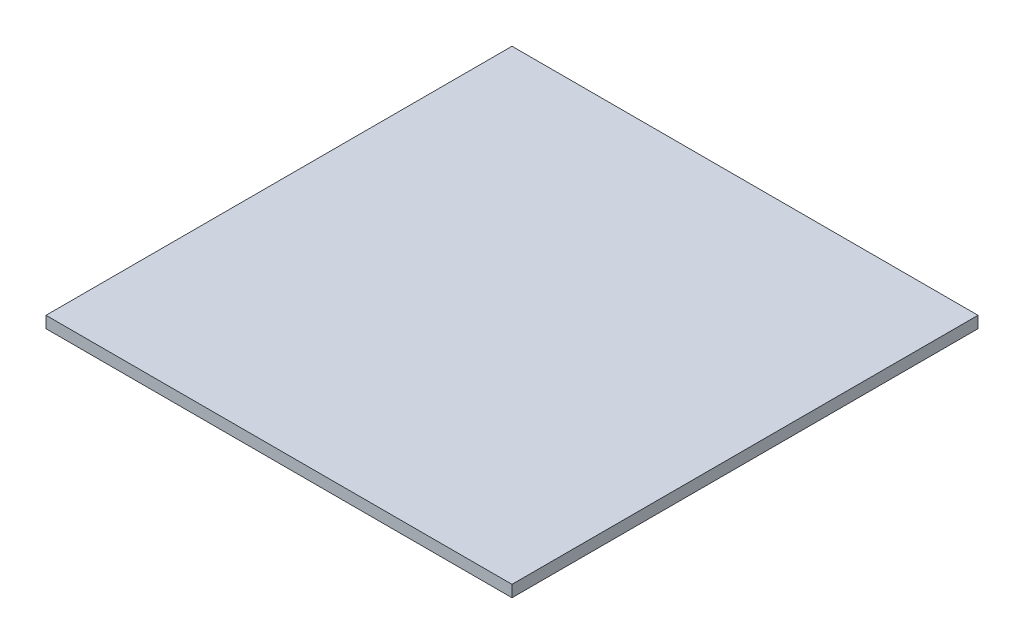
from build123d import *

# Parameters (mm, degrees)
SKETCH_1_W      = 80
SKETCH_1_H      = 80
EXTRUDE_1_DEPTH = 2


with BuildPart() as part:
    # 草图1 → 凸台-拉伸1 (new body)
    with BuildSketch(Plane(origin=(0, 0, 0), x_dir=(1, 0, 0), z_dir=(0, 1, 0))):
        Rectangle(SKETCH_1_W, SKETCH_1_H)
    extrude(amount=EXTRUDE_1_DEPTH)


solid = part.part
